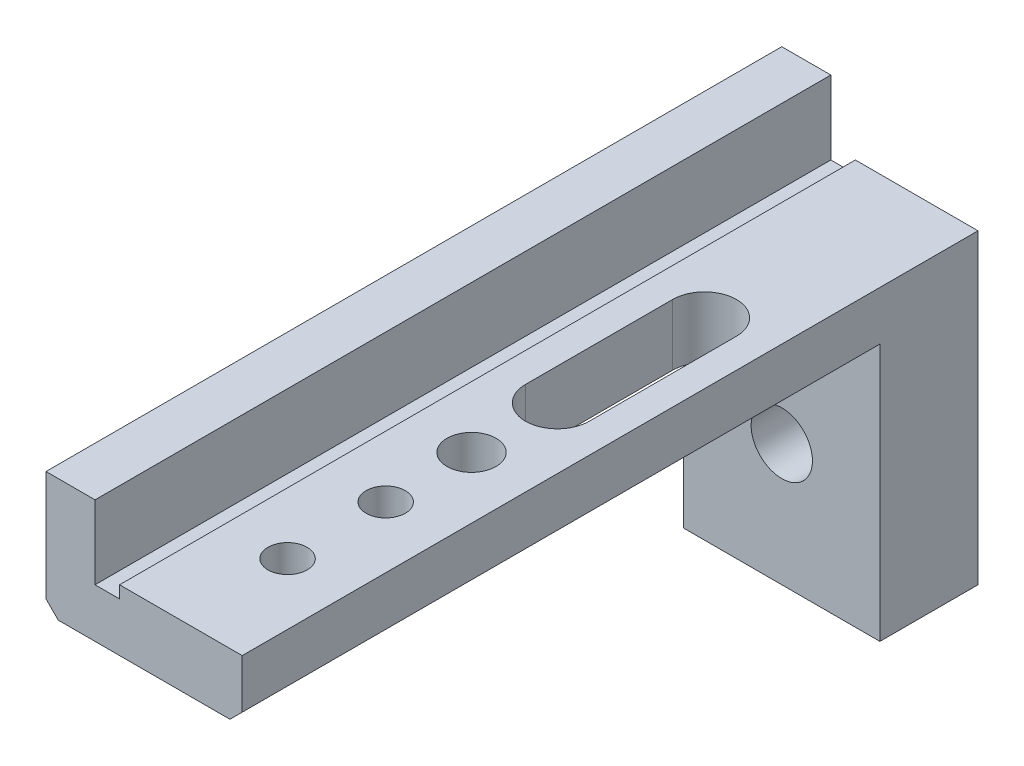
from build123d import *

# Parameters (mm, degrees)
BOSS_EXTRUDE1_DEPTH   = 30
SKETCH2_W             = 8
SKETCH2_H             = 4
BOSS_EXTRUDE2_DEPTH   = 10
SKETCH3_R             = 1
CUT_EXTRUDE1_DEPTH    = 10
M2_TAPPED_HOLE1_D     = 1.6
M2_TAPPED_HOLE1_DEPTH = 5.2
M2_TAPPED_HOLE1_TIP   = 0.480688495
M3_TAPPED_HOLE1_D     = 2.5
M3_TAPPED_HOLE1_DEPTH = 7.5
M3_TAPPED_HOLE1_TIP   = 0.751075774
CHAMFER1_SIZE         = 0.5


with BuildPart() as part:
    # Sketch1 → Boss-Extrude1 (new body)
    with BuildSketch(Plane.XY):
        Polygon((-5.152542373, 3), (-3.152542373, 3), (-3.152542373, 0), (-2.152542373, 0), (-2.152542373, 0.5), (2.847457627, 0.5), (2.847457627, -2), (-5.152542373, -2), align=None)
    extrude(amount=BOSS_EXTRUDE1_DEPTH)

    # Sketch2 → Boss-Extrude2 (add)
    with BuildSketch(Plane.XZ.offset(2)):
        with Locations((-1.152542373, 2)):
            Rectangle(SKETCH2_W, SKETCH2_H)
    extrude(amount=BOSS_EXTRUDE2_DEPTH)

    # Sketch3 → Cut-Extrude1 (cut)
    with BuildSketch(Plane(origin=(0, 0.5, 0), x_dir=(1, 0, 0), z_dir=(0, 1, 0))):
        with Locations((0.347457627, -18.15)):
            Circle(SKETCH3_R)
        with BuildLine():
            Line((-0.952542373, -14.65), (-0.952542373, -8.65))
            ThreePointArc((-0.952542373, -8.65), (0.347457627, -7.35), (1.647457627, -8.65))
            Line((1.647457627, -8.65), (1.647457627, -14.65))
            ThreePointArc((1.647457627, -14.65), (0.347457627, -15.95), (-0.952542373, -14.65))
        make_face()
    extrude(amount=-CUT_EXTRUDE1_DEPTH, mode=Mode.SUBTRACT)

    # M2 Tapped Hole1
    with Locations(Plane(origin=(0, 0.5, 0), x_dir=(1, 0, 0), z_dir=(0, 1, 0))):
        with Locations((0.347457627, -21.65), (0.347457627, -25.65)):
            Hole(M2_TAPPED_HOLE1_D / 2, depth=M2_TAPPED_HOLE1_DEPTH)
            with Locations((0, 0, -(M2_TAPPED_HOLE1_DEPTH + M2_TAPPED_HOLE1_TIP / 2))):  # 118° drill point
                Cone(0, M2_TAPPED_HOLE1_D / 2, M2_TAPPED_HOLE1_TIP, mode=Mode.SUBTRACT)

    # M3 Tapped Hole1
    with Locations(Plane.XY.offset(4)):
        with Locations((-1.152542373, -7)):
            Hole(M3_TAPPED_HOLE1_D / 2, depth=M3_TAPPED_HOLE1_DEPTH)
            with Locations((0, 0, -(M3_TAPPED_HOLE1_DEPTH + M3_TAPPED_HOLE1_TIP / 2))):  # 118° drill point
                Cone(0, M3_TAPPED_HOLE1_D / 2, M3_TAPPED_HOLE1_TIP, mode=Mode.SUBTRACT)

    # Chamfer1
    chamfer1_edges = [part.edges().sort_by_distance(p)[0] for p in [
        (2.847457627, -2, 17),
        (-5.152542373, -2, 17),
    ]]
    chamfer(chamfer1_edges, length=CHAMFER1_SIZE)


solid = part.part
